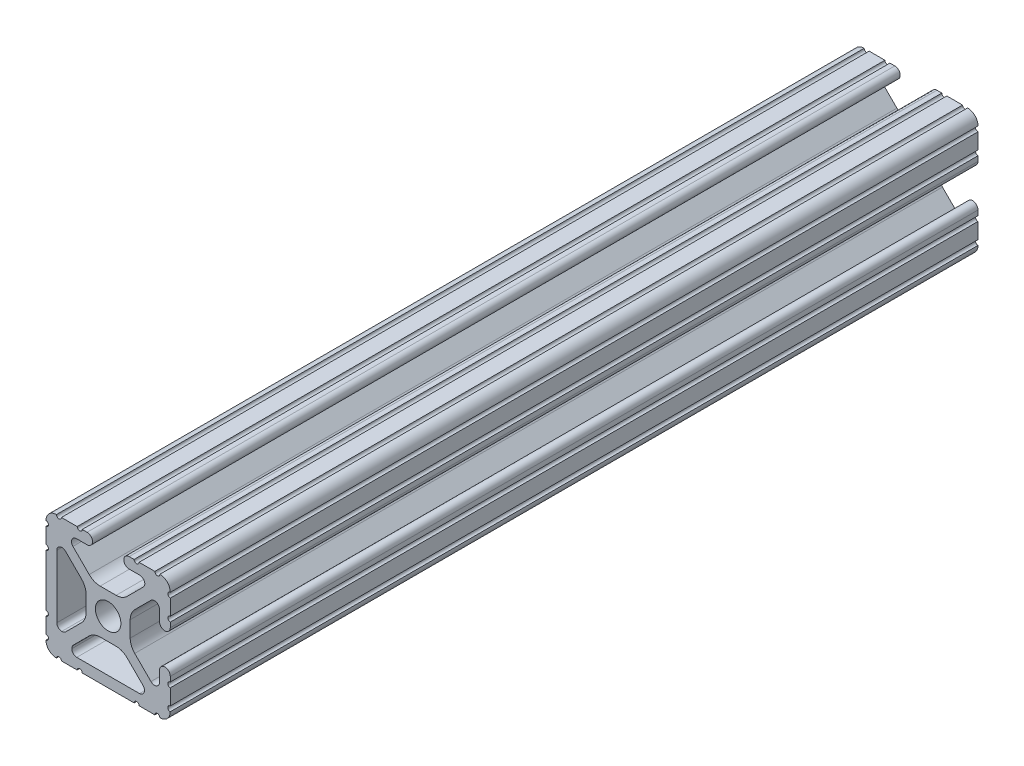
from build123d import *

# Parameters (mm, degrees)
SKETCH1_R           = 2.6035
BOSS_EXTRUDE1_DEPTH = 165.1


with BuildPart() as part:
    # Sketch1 → Boss-Extrude1 (new body)
    with BuildSketch(Plane(origin=(0, 0, -558.8), x_dir=(-1, 0, 0), z_dir=(0, 0, -1))):
        with BuildLine():
            Line((12.699999967, -9.5504), (12.699999967, -6.3246))
            ThreePointArc((12.699999967, -6.3246), (12.191999967, -5.8166), (12.699999967, -5.3086))
            Line((12.699999967, -5.3086), (12.699999967, 5.3086))
            ThreePointArc((12.699999967, 5.3086), (12.191999967, 5.8166), (12.699999967, 6.3246))
            Line((12.699999967, 6.3246), (12.699999967, 9.550399967))
            ThreePointArc((12.699999967, 9.550399967), (12.191999934, 10.058400016), (12.699999999, 10.566400033))
            ThreePointArc((12.699999999, 10.566400033), (12.082677404, 12.082677438), (10.566399999, 12.700000033))
            ThreePointArc((10.566399999, 12.700000033), (10.058400007, 12.192000016), (9.550399999, 12.700000016))
            Line((9.550399999, 12.700000016), (6.324599999, 12.700000016))
            ThreePointArc((6.324599999, 12.700000016), (5.816599999, 12.192000016), (5.308599999, 12.700000016))
            Line((5.308599999, 12.700000016), (4.302307888, 12.700000016))
            ThreePointArc((4.302307888, 12.700000016), (3.197407888, 11.595100016), (4.302307888, 10.490200016))
            Line((4.302307888, 10.490200016), (6.474794464, 10.490200016))
            ThreePointArc((6.474794464, 10.490200016), (7.413456072, 9.863006381), (7.193214956, 8.755779521))
            Line((7.193214956, 8.755779521), (3.875871421, 5.438435986))
            ThreePointArc((3.875871421, 5.438435986), (2.845827288, 4.7501825), (1.63080739, 4.508500016))
            Line((1.63080739, 4.508500016), (-1.630807376, 4.508500016))
            ThreePointArc((-1.630807376, 4.508500016), (-2.845827273, 4.7501825), (-3.875871406, 5.438435986))
            Line((-3.875871406, 5.438435986), (-7.193214947, 8.755779526))
            ThreePointArc((-7.193214947, 8.755779526), (-7.413456062, 9.863006383), (-6.474794457, 10.490200016))
            Line((-6.474794457, 10.490200016), (-4.302307919, 10.490200016))
            ThreePointArc((-4.302307919, 10.490200016), (-3.197407919, 11.595100016), (-4.302307919, 12.700000016))
            Line((-4.302307919, 12.700000016), (-5.308600001, 12.700000016))
            ThreePointArc((-5.308600001, 12.700000016), (-5.816600001, 12.192000016), (-6.324600001, 12.700000016))
            Line((-6.324600001, 12.700000016), (-9.550400001, 12.700000016))
            ThreePointArc((-9.550400001, 12.700000016), (-10.058400001, 12.192000016), (-10.566400001, 12.700000016))
            ThreePointArc((-10.566400001, 12.700000016), (-12.082677418, 12.082677417), (-12.700000017, 10.5664))
            ThreePointArc((-12.700000017, 10.5664), (-12.192, 10.058400008), (-12.7, 9.5504))
            Line((-12.7, 9.5504), (-12.7, 6.3246))
            ThreePointArc((-12.7, 6.3246), (-12.192, 5.8166), (-12.7, 5.3086))
            Line((-12.7, 5.3086), (-12.7, 4.302307889))
            ThreePointArc((-12.7, 4.302307889), (-11.5951, 3.197407889), (-10.4902, 4.302307889))
            Line((-10.4902, 4.302307889), (-10.4902, 6.474794456))
            ThreePointArc((-10.4902, 6.474794456), (-9.863006367, 7.413456061), (-8.75577951, 7.193214945))
            Line((-8.75577951, 7.193214945), (-5.43843597, 3.875871405))
            ThreePointArc((-5.43843597, 3.875871405), (-4.750182484, 2.845827272), (-4.5085, 1.630807374))
            Line((-4.5085, 1.630807374), (-4.5085, -1.630807374))
            ThreePointArc((-4.5085, -1.630807374), (-4.750182484, -2.845827272), (-5.43843597, -3.875871405))
            Line((-5.43843597, -3.875871405), (-8.75577951, -7.193214945))
            ThreePointArc((-8.75577951, -7.193214945), (-9.863006367, -7.413456061), (-10.4902, -6.474794456))
            Line((-10.4902, -6.474794456), (-10.4902, -4.302307918))
            ThreePointArc((-10.4902, -4.302307918), (-11.5951, -3.197407918), (-12.7, -4.302307918))
            Line((-12.7, -4.302307918), (-12.7, -5.3086))
            ThreePointArc((-12.7, -5.3086), (-12.192, -5.8166), (-12.7, -6.3246))
            Line((-12.7, -6.3246), (-12.7, -9.5504))
            ThreePointArc((-12.7, -9.5504), (-12.192, -10.058400008), (-12.700000017, -10.5664))
            ThreePointArc((-12.700000017, -10.5664), (-12.082677422, -12.082677406), (-10.566400017, -12.7))
            ThreePointArc((-10.566400017, -12.7), (-10.058400017, -12.192), (-9.550400017, -12.7))
            Line((-9.550400017, -12.7), (-6.324600017, -12.7))
            ThreePointArc((-6.324600017, -12.7), (-5.816600017, -12.192), (-5.308600017, -12.7))
            Line((-5.308600017, -12.7), (5.308599983, -12.7))
            ThreePointArc((5.308599983, -12.7), (5.816599983, -12.192), (6.324599983, -12.7))
            Line((6.324599983, -12.7), (9.550399983, -12.7))
            ThreePointArc((9.550399983, -12.7), (10.058399983, -12.192), (10.566399983, -12.7))
            ThreePointArc((10.566399983, -12.7), (12.082677389, -12.082677406), (12.699999983, -10.5664))
            ThreePointArc((12.699999983, -10.5664), (12.191999967, -10.058400008), (12.699999967, -9.5504))
        make_face()
        Circle(SKETCH1_R, mode=Mode.SUBTRACT)
        with BuildLine():
            Line((3.875871405, -5.43843597), (7.13192049, -8.694485055))
            ThreePointArc((7.13192049, -8.694485055), (7.35441848, -9.056211656), (7.4295, -9.4742))
            ThreePointArc((7.4295, -9.4742), (7.13192049, -10.19262049), (6.4135, -10.4902))
            Line((6.4135, -10.4902), (-6.4135, -10.4902))
            ThreePointArc((-6.4135, -10.4902), (-7.13192049, -10.19262049), (-7.4295, -9.4742))
            ThreePointArc((-7.4295, -9.4742), (-7.35441848, -9.056211656), (-7.13192049, -8.694485055))
            Line((-7.13192049, -8.694485055), (-3.875871405, -5.43843597))
            ThreePointArc((-3.875871405, -5.43843597), (-2.845827272, -4.750182484), (-1.630807374, -4.5085))
            Line((-1.630807374, -4.5085), (1.630807374, -4.5085))
            ThreePointArc((1.630807374, -4.5085), (2.845827272, -4.750182484), (3.875871405, -5.43843597))
        make_face(mode=Mode.SUBTRACT)
        with BuildLine():
            Line((10.490199999, 6.4135), (10.490199999, -6.413499984))
            ThreePointArc((10.490199999, -6.413499984), (10.192620488, -7.131920474), (9.474199999, -7.429499984))
            ThreePointArc((9.474199999, -7.429499984), (9.056211655, -7.354418464), (8.694485053, -7.131920474))
            Line((8.694485053, -7.131920474), (5.438435968, -3.875871389))
            ThreePointArc((5.438435968, -3.875871389), (4.750182483, -2.845827256), (4.508499999, -1.630807359))
            Line((4.508499999, -1.630807359), (4.508499999, 1.630807373))
            ThreePointArc((4.508499999, 1.630807373), (4.750182483, 2.845827271), (5.438435968, 3.875871403))
            Line((5.438435968, 3.875871403), (8.694485055, 7.13192049))
            ThreePointArc((8.694485055, 7.13192049), (9.056211656, 7.35441848), (9.4742, 7.4295))
            ThreePointArc((9.4742, 7.4295), (10.192620489, 7.131920489), (10.490199999, 6.4135))
        make_face(mode=Mode.SUBTRACT)
    extrude(amount=-BOSS_EXTRUDE1_DEPTH)


solid = part.part
